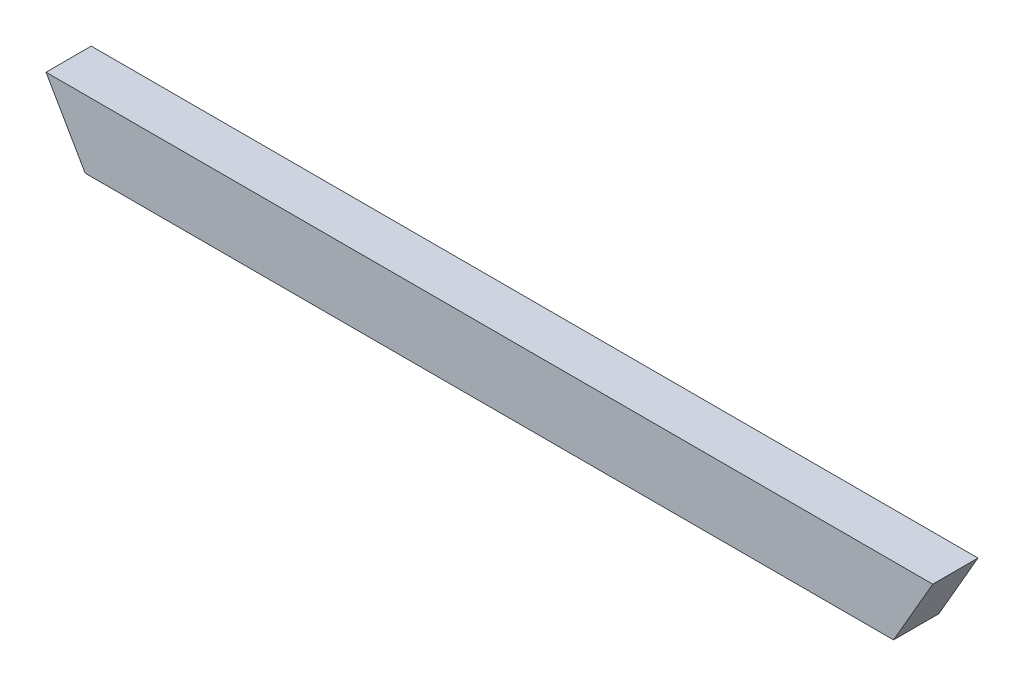
from build123d import *

# Parameters (mm, degrees)
BOSS_EXTRUDE1_DEPTH = 25.4


with BuildPart() as part:
    # Sketch1 → Boss-Extrude1 (new body)
    with BuildSketch(Plane.XY):
        Polygon((248.868157838, 0), (237.86963521, -19.05), (-215.872589954, -19.05), (-237.86963521, 19.05), (259.866680466, 19.05), align=None)
    extrude(amount=BOSS_EXTRUDE1_DEPTH)


solid = part.part
